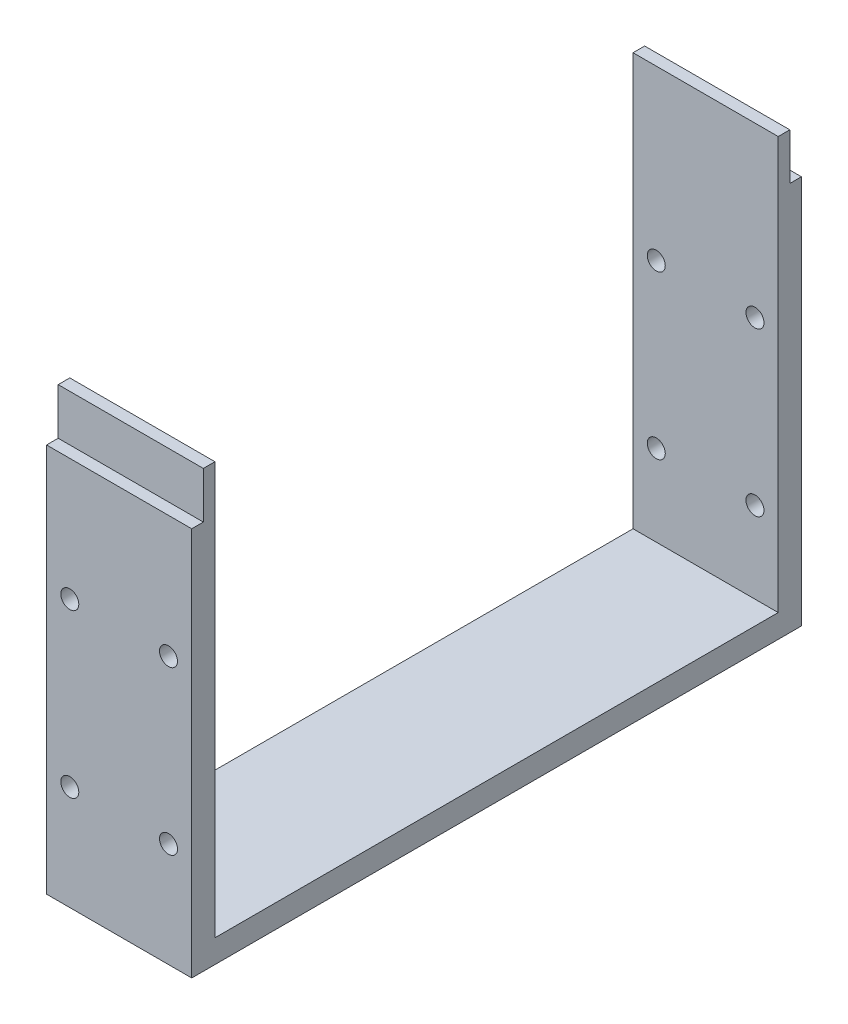
from build123d import *

# Parameters (mm, degrees)
SKETCH1_W               = 105
SKETCH1_H               = 4
SKETCH1_W_2             = 2
SKETCH1_H_2             = 8
BOSS_EXTRUDE1_DEPTH     = 12.5
SKETCH2_R               = 1.55
CUT_EXTRUDE2_DEPTH      = 102
CUT_EXTRUDE2_DEPTH_BACK = 5


with BuildPart() as part:
    # Sketch1 → Boss-Extrude1 (new body, symmetric)
    with BuildSketch(Plane(origin=(0, 0, 0), x_dir=(0, 0, -1), z_dir=(1, 0, 0))):
        Rectangle(SKETCH1_W, SKETCH1_H)
        Polygon((-52.5, 65), (-52.5, 2), (-48.5, 2), (-48.5, 65), (-50.5, 65), align=None)
        Polygon((48.5, 65), (48.5, 2), (52.5, 2), (52.5, 65), (50.5, 65), align=None)
        with Locations((-49.5, 69)):
            Rectangle(SKETCH1_W_2, SKETCH1_H_2)
        with Locations((49.5, 69)):
            Rectangle(SKETCH1_W_2, SKETCH1_H_2)
    extrude(amount=BOSS_EXTRUDE1_DEPTH, both=True)

    # Sketch2 → Cut-Extrude2 (cut, two sides)
    with BuildSketch(Plane(origin=(0, 0, 48.5), x_dir=(-1, 0, 0), z_dir=(0, 0, -1))) as cut_extrude2_sk:
        with Locations((-8.5, 16)):
            Circle(SKETCH2_R)
        with Locations((-8.5, 44)):
            Circle(SKETCH2_R)
        with Locations((8.5, 16)):
            Circle(SKETCH2_R)
        with Locations((8.5, 44)):
            Circle(SKETCH2_R)
    extrude(amount=CUT_EXTRUDE2_DEPTH, mode=Mode.SUBTRACT)
    extrude(cut_extrude2_sk.sketch, amount=-CUT_EXTRUDE2_DEPTH_BACK, mode=Mode.SUBTRACT)


solid = part.part
